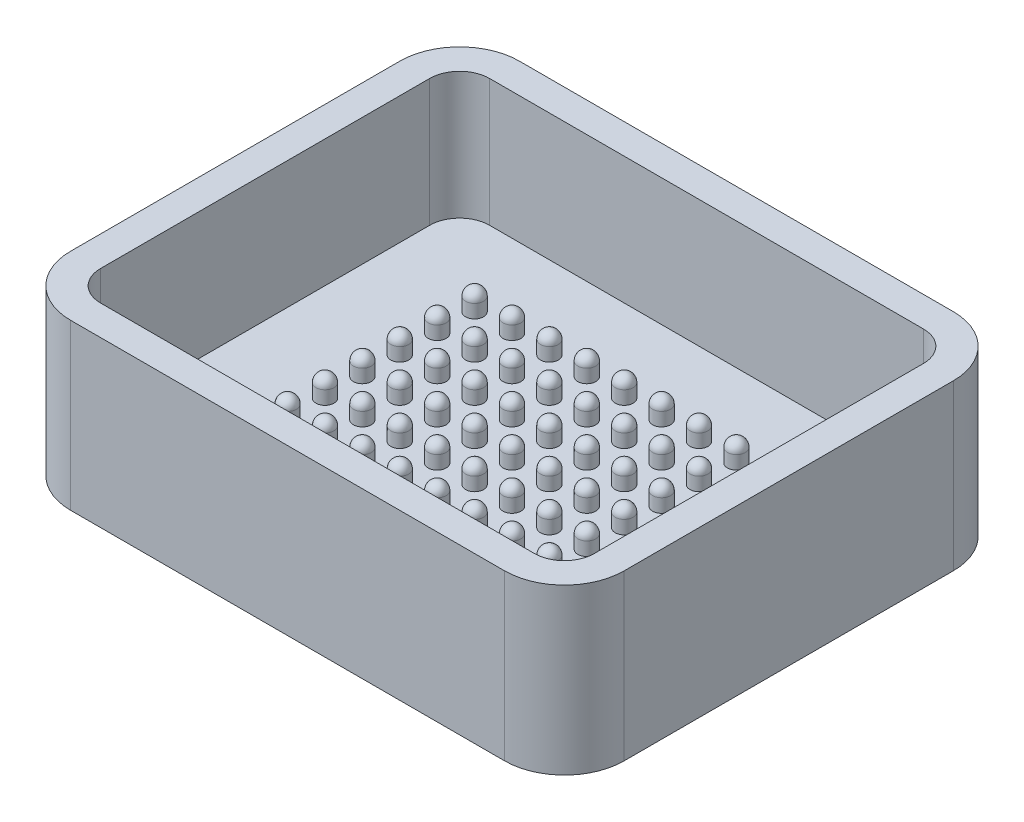
from build123d import *

# Parameters (mm, degrees)
SKETCH_1_W      = 33
SKETCH_1_H      = 26
EXTRUDE_1_DEPTH = 2.5
SKETCH_2_R      = 0.6
EXTRUDE_2_DEPTH = 1.5
FILLET_1_R      = 0.6
SKETCH_3_W      = 37
SKETCH_3_H      = 30
SKETCH_3_W_2    = 33
SKETCH_3_H_2    = 26
EXTRUDE_3_DEPTH = 11
FILLET_3_R      = 2
FILLET_4_R      = 4


with BuildPart() as part:
    # 草图1 → 凸台-拉伸1 (new body)
    with BuildSketch(Plane(origin=(0, 0, 0), x_dir=(1, 0, 0), z_dir=(0, 1, 0))):
        Rectangle(SKETCH_1_W, SKETCH_1_H)
    extrude(amount=EXTRUDE_1_DEPTH)

    # 草图2 → 凸台-拉伸2 (add)
    with BuildSketch(Plane(origin=(0, 2.5, 0), x_dir=(1, 0, 0), z_dir=(0, 1, 0))):
        Circle(SKETCH_2_R)
        with Locations((2.5, 0)):
            Circle(SKETCH_2_R)
        with Locations((5, 0)):
            Circle(SKETCH_2_R)
        with Locations((7.5, 0)):
            Circle(SKETCH_2_R)
        with Locations((10, 0)):
            Circle(SKETCH_2_R)
        with Locations((2.5, 2.5)):
            Circle(SKETCH_2_R)
        with Locations((5, 2.5)):
            Circle(SKETCH_2_R)
        with Locations((7.5, 2.5)):
            Circle(SKETCH_2_R)
        with Locations((10, 2.5)):
            Circle(SKETCH_2_R)
        with Locations((2.5, 5)):
            Circle(SKETCH_2_R)
        with Locations((5, 5)):
            Circle(SKETCH_2_R)
        with Locations((7.5, 5)):
            Circle(SKETCH_2_R)
        with Locations((10, 5)):
            Circle(SKETCH_2_R)
        with Locations((2.5, 7.5)):
            Circle(SKETCH_2_R)
        with Locations((5, 7.5)):
            Circle(SKETCH_2_R)
        with Locations((7.5, 7.5)):
            Circle(SKETCH_2_R)
        with Locations((10, 7.5)):
            Circle(SKETCH_2_R)
        with Locations((0, 2.5)):
            Circle(SKETCH_2_R)
        with Locations((0, 5)):
            Circle(SKETCH_2_R)
        with Locations((0, 7.5)):
            Circle(SKETCH_2_R)
        with Locations((10, -7.5)):
            Circle(SKETCH_2_R)
        with Locations((7.5, -7.5)):
            Circle(SKETCH_2_R)
        with Locations((5, -7.5)):
            Circle(SKETCH_2_R)
        with Locations((2.5, -7.5)):
            Circle(SKETCH_2_R)
        with Locations((10, -5)):
            Circle(SKETCH_2_R)
        with Locations((7.5, -5)):
            Circle(SKETCH_2_R)
        with Locations((5, -5)):
            Circle(SKETCH_2_R)
        with Locations((2.5, -5)):
            Circle(SKETCH_2_R)
        with Locations((10, -2.5)):
            Circle(SKETCH_2_R)
        with Locations((7.5, -2.5)):
            Circle(SKETCH_2_R)
        with Locations((5, -2.5)):
            Circle(SKETCH_2_R)
        with Locations((2.5, -2.5)):
            Circle(SKETCH_2_R)
        with Locations((-2.5, -2.5)):
            Circle(SKETCH_2_R)
        with Locations((-5, -2.5)):
            Circle(SKETCH_2_R)
        with Locations((-7.5, -2.5)):
            Circle(SKETCH_2_R)
        with Locations((-10, -2.5)):
            Circle(SKETCH_2_R)
        with Locations((-2.5, -5)):
            Circle(SKETCH_2_R)
        with Locations((-5, -5)):
            Circle(SKETCH_2_R)
        with Locations((-7.5, -5)):
            Circle(SKETCH_2_R)
        with Locations((-10, -5)):
            Circle(SKETCH_2_R)
        with Locations((-2.5, -7.5)):
            Circle(SKETCH_2_R)
        with Locations((-5, -7.5)):
            Circle(SKETCH_2_R)
        with Locations((-7.5, -7.5)):
            Circle(SKETCH_2_R)
        with Locations((-10, -7.5)):
            Circle(SKETCH_2_R)
        with Locations((-10, 7.5)):
            Circle(SKETCH_2_R)
        with Locations((-7.5, 7.5)):
            Circle(SKETCH_2_R)
        with Locations((-5, 7.5)):
            Circle(SKETCH_2_R)
        with Locations((-2.5, 7.5)):
            Circle(SKETCH_2_R)
        with Locations((-10, 5)):
            Circle(SKETCH_2_R)
        with Locations((-7.5, 5)):
            Circle(SKETCH_2_R)
        with Locations((-5, 5)):
            Circle(SKETCH_2_R)
        with Locations((-2.5, 5)):
            Circle(SKETCH_2_R)
        with Locations((-10, 2.5)):
            Circle(SKETCH_2_R)
        with Locations((-7.5, 2.5)):
            Circle(SKETCH_2_R)
        with Locations((-5, 2.5)):
            Circle(SKETCH_2_R)
        with Locations((-2.5, 2.5)):
            Circle(SKETCH_2_R)
        with Locations((-10, 0)):
            Circle(SKETCH_2_R)
        with Locations((-7.5, 0)):
            Circle(SKETCH_2_R)
        with Locations((-5, 0)):
            Circle(SKETCH_2_R)
        with Locations((-2.5, 0)):
            Circle(SKETCH_2_R)
        with Locations((0, -7.5)):
            Circle(SKETCH_2_R)
        with Locations((0, -5)):
            Circle(SKETCH_2_R)
        with Locations((0, -2.5)):
            Circle(SKETCH_2_R)
    extrude(amount=EXTRUDE_2_DEPTH)

    # 圆角1
    fillet_1_edges = [part.edges().sort_by_distance(p)[0] for p in [
        (9.4, 4, 2.5),
        (6.9, 4, 2.5),
        (4.4, 4, 2.5),
        (1.9, 4, 2.5),
        (-3.1, 4, 2.5),
        (-5.6, 4, 2.5),
        (-8.1, 4, 2.5),
        (-10.6, 4, 2.5),
        (-3.1, 4, 5),
        (-5.6, 4, 5),
        (-8.1, 4, 5),
        (-10.6, 4, 5),
        (-3.1, 4, 7.5),
        (-5.6, 4, 7.5),
        (-8.1, 4, 7.5),
        (-10.6, 4, 7.5),
        (-0.6, 4, 0),
        (-10.6, 4, -7.5),
        (-8.1, 4, -7.5),
        (-5.6, 4, -7.5),
        (-3.1, 4, -7.5),
        (-10.6, 4, -5),
        (-8.1, 4, -5),
        (-5.6, 4, -5),
        (-3.1, 4, -5),
        (-10.6, 4, -2.5),
        (-8.1, 4, -2.5),
        (1.9, 4, 0),
        (-5.6, 4, -2.5),
        (-3.1, 4, -2.5),
        (-10.6, 4, 0),
        (-8.1, 4, 0),
        (-5.6, 4, 0),
        (-3.1, 4, 0),
        (-0.6, 4, 7.5),
        (-0.6, 4, 5),
        (-0.6, 4, 2.5),
        (4.4, 4, 0),
        (6.9, 4, 0),
        (9.4, 4, 0),
        (1.9, 4, -2.5),
        (4.4, 4, -2.5),
        (6.9, 4, -2.5),
        (9.4, 4, -2.5),
        (1.9, 4, -5),
        (4.4, 4, -5),
        (6.9, 4, -5),
        (9.4, 4, -5),
        (1.9, 4, -7.5),
        (4.4, 4, -7.5),
        (6.9, 4, -7.5),
        (9.4, 4, -7.5),
        (-0.6, 4, -2.5),
        (-0.6, 4, -5),
        (-0.6, 4, -7.5),
        (9.4, 4, 7.5),
        (6.9, 4, 7.5),
        (4.4, 4, 7.5),
        (1.9, 4, 7.5),
        (9.4, 4, 5),
        (6.9, 4, 5),
        (4.4, 4, 5),
        (1.9, 4, 5),
    ]]
    fillet(fillet_1_edges, radius=FILLET_1_R)

    # 草图3 → 凸台-拉伸3 (add)
    with BuildSketch(Plane.XZ):
        Rectangle(SKETCH_3_W, SKETCH_3_H)
        Rectangle(SKETCH_3_W_2, SKETCH_3_H_2, mode=Mode.SUBTRACT)
    extrude(amount=-EXTRUDE_3_DEPTH)

    # 圆角3
    fillet_3_edges = [part.edges().sort_by_distance(p)[0] for p in [
        (16.5, 6.75, -13),
        (-16.5, 6.75, -13),
        (-16.5, 6.75, 13),
        (16.5, 6.75, 13),
    ]]
    fillet(fillet_3_edges, radius=FILLET_3_R)

    # 圆角4
    fillet_4_edges = [part.edges().sort_by_distance(p)[0] for p in [
        (18.5, 5.5, 15),
        (18.5, 5.5, -15),
        (-18.5, 5.5, -15),
        (-18.5, 5.5, 15),
    ]]
    fillet(fillet_4_edges, radius=FILLET_4_R)


solid = part.part
